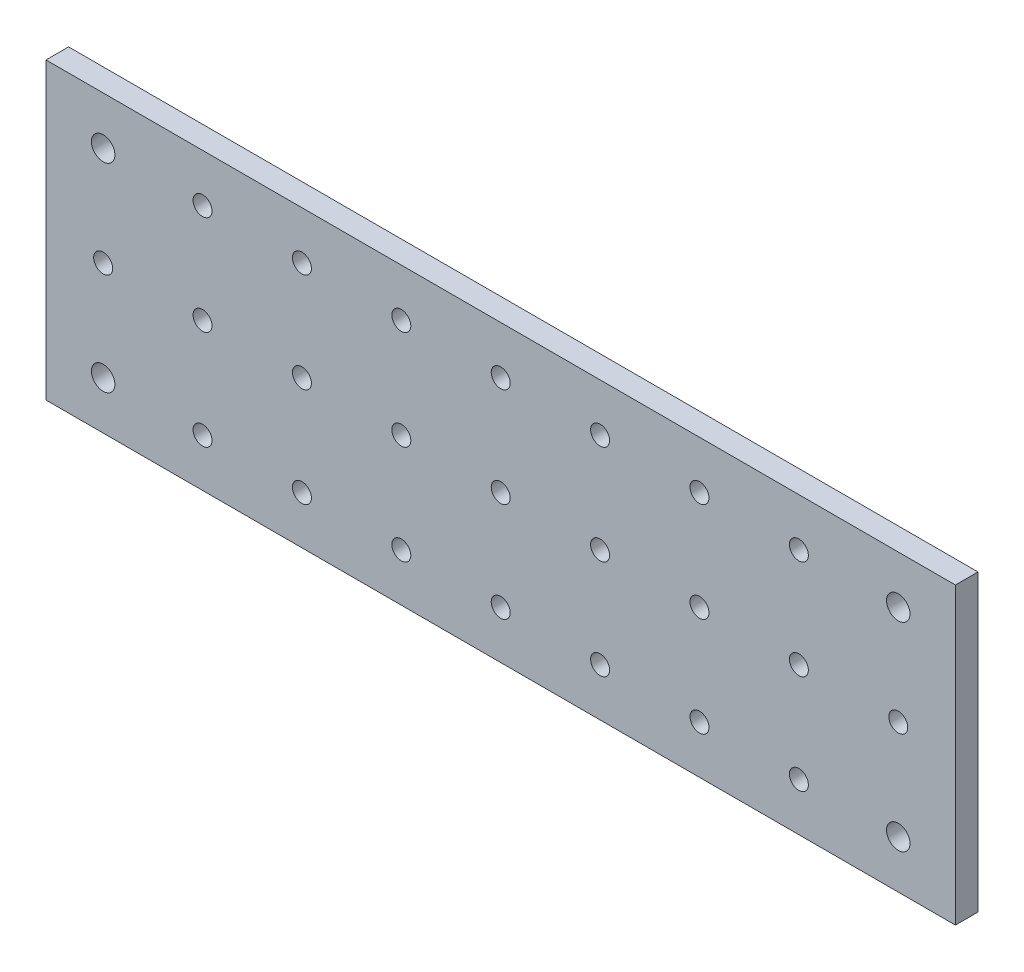
from build123d import *

# Parameters (mm, degrees)
ESBO_O1_W                  = 201.3
ESBO_O1_H                  = 65.2
RESSALTO_EXTRUS_O1_DEPTH   = 5
ESBO_O2_R                  = 2.1
CORTE_EXTRUS_O1_DEPTH      = 30
ESBO_O3_R                  = 2.6
CORTE_EXTRUS_O2_DEPTH      = 28
CORTE_EXTRUS_O2_DEPTH_BACK = 22


with BuildPart() as part:
    # Esboço1 → Ressalto-extrusão1 (new body)
    with BuildSketch(Plane.XY):
        with Locations((100.65, 32.6)):
            Rectangle(ESBO_O1_W, ESBO_O1_H)
    extrude(amount=RESSALTO_EXTRUS_O1_DEPTH)

    # Esboço2 → Corte-extrusão1 (cut)
    with BuildSketch(Plane.XY):
        with Locations((100.65, 32.6)):
            Circle(ESBO_O2_R)
        with Locations((100.65, 54.6)):
            Circle(ESBO_O2_R)
        with Locations((100.65, 10.6)):
            Circle(ESBO_O2_R)
        with Locations((122.65, 32.6)):
            Circle(ESBO_O2_R)
        with Locations((122.65, 54.6)):
            Circle(ESBO_O2_R)
        with Locations((122.65, 10.6)):
            Circle(ESBO_O2_R)
        with Locations((144.65, 32.6)):
            Circle(ESBO_O2_R)
        with Locations((144.65, 54.6)):
            Circle(ESBO_O2_R)
        with Locations((144.65, 10.6)):
            Circle(ESBO_O2_R)
        with Locations((166.65, 32.6)):
            Circle(ESBO_O2_R)
        with Locations((166.65, 54.6)):
            Circle(ESBO_O2_R)
        with Locations((166.65, 10.6)):
            Circle(ESBO_O2_R)
        with Locations((188.65, 32.6)):
            Circle(ESBO_O2_R)
        with Locations((188.65, 54.6)):
            Circle(ESBO_O2_R)
        with Locations((188.65, 10.6)):
            Circle(ESBO_O2_R)
        with Locations((78.65, 32.6)):
            Circle(ESBO_O2_R)
        with Locations((78.65, 54.6)):
            Circle(ESBO_O2_R)
        with Locations((78.65, 10.6)):
            Circle(ESBO_O2_R)
        with Locations((56.65, 32.6)):
            Circle(ESBO_O2_R)
        with Locations((56.65, 54.6)):
            Circle(ESBO_O2_R)
        with Locations((56.65, 10.6)):
            Circle(ESBO_O2_R)
        with Locations((34.65, 32.6)):
            Circle(ESBO_O2_R)
        with Locations((34.65, 54.6)):
            Circle(ESBO_O2_R)
        with Locations((34.65, 10.6)):
            Circle(ESBO_O2_R)
        with Locations((12.65, 32.6)):
            Circle(ESBO_O2_R)
        with Locations((12.65, 54.6)):
            Circle(ESBO_O2_R)
        with Locations((12.65, 10.6)):
            Circle(ESBO_O2_R)
    extrude(amount=CORTE_EXTRUS_O1_DEPTH, mode=Mode.SUBTRACT)

    # Esboço3 → Corte-extrusão2 (cut, two sides)
    with BuildSketch(Plane(origin=(0, 0, 0), x_dir=(-1, 0, 0), z_dir=(0, 0, -1))) as corte_extrus_o2_sk:
        with Locations((-188.65, 54.6)):
            Circle(ESBO_O3_R)
        with Locations((-12.65, 54.6)):
            Circle(ESBO_O3_R)
        with Locations((-12.65, 10.6)):
            Circle(ESBO_O3_R)
        with Locations((-188.65, 10.6)):
            Circle(ESBO_O3_R)
    extrude(amount=CORTE_EXTRUS_O2_DEPTH, mode=Mode.SUBTRACT)
    extrude(corte_extrus_o2_sk.sketch, amount=-CORTE_EXTRUS_O2_DEPTH_BACK, mode=Mode.SUBTRACT)


solid = part.part
